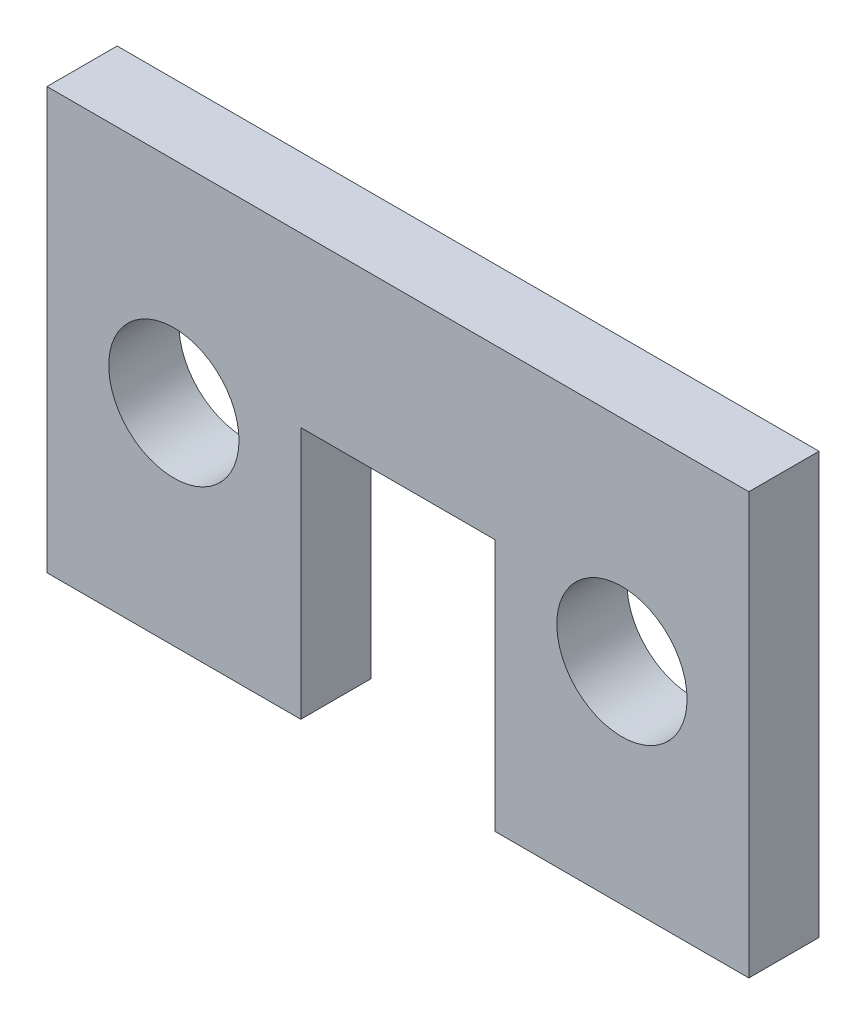
from build123d import *

# Parameters (mm, degrees)
BOSS_EXTRUDE1_DEPTH   = 1.5875
F_4_CLEARANCE_HOLE1_D = 2.9464


with BuildPart() as part:
    # Sketch2 → Boss-Extrude1 (new body)
    with BuildSketch(Plane.XY):
        Polygon((-2.1971, 2.8575), (2.1971, 2.8575), (2.1971, -2.8575), (7.9375, -2.8575), (7.9375, 6.6675), (-7.9375, 6.6675), (-7.9375, -2.8575), (-2.1971, -2.8575), align=None)
    extrude(amount=BOSS_EXTRUDE1_DEPTH)

    # #4 Clearance Hole1 (through all)
    with Locations(Plane.XY.offset(1.5875)):
        with Locations((-5.0673, 1.905), (5.0673, 1.905)):
            Hole(F_4_CLEARANCE_HOLE1_D / 2)


solid = part.part
